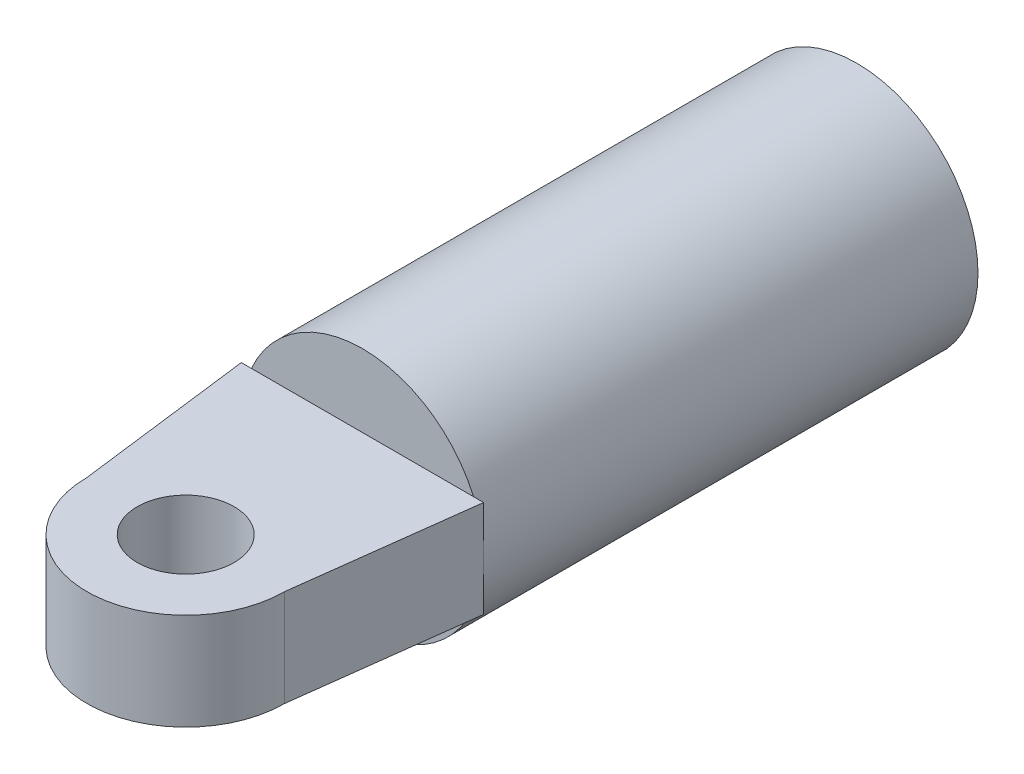
from build123d import *

# Parameters (mm, degrees)
SKETCH_1_R           = 12.5
EXTRUDE_1_DEPTH      = 51
EXTRUDE_2_DEPTH      = 5
EXTRUDE_2_DEPTH_BACK = 5
SKETCH_2_R           = 4.999511077


with BuildPart() as part:
    # Эскиз1 → Бобышка-Вытянуть1 (new body)
    with BuildSketch(Plane.XY):
        Circle(SKETCH_1_R)
    extrude(amount=EXTRUDE_1_DEPTH)

    # Эскиз2 → Бобышка-Вытянуть2 (add, two sides: drawn at the far end of the back side and taken through both)
    with BuildSketch(Plane(origin=(0, 0, 0), x_dir=(0, 0, -1), z_dir=(0, 1, 0)).offset(-EXTRUDE_2_DEPTH_BACK)):
        with BuildLine():
            Line((-69.235394105, 10.194154198), (-51, 12.5))
            Line((-51, 12.5), (-51, -12.5))
            Line((-51, -12.5), (-69.235394105, -10.194154198))
            ThreePointArc((-69.235394105, -10.194154198), (-79.429548303, 0), (-69.235394105, 10.194154198))
        make_face()
        with Locations((-69.235394105, 0)):
            Circle(SKETCH_2_R, mode=Mode.SUBTRACT)
    extrude(amount=EXTRUDE_2_DEPTH + EXTRUDE_2_DEPTH_BACK)


solid = part.part
